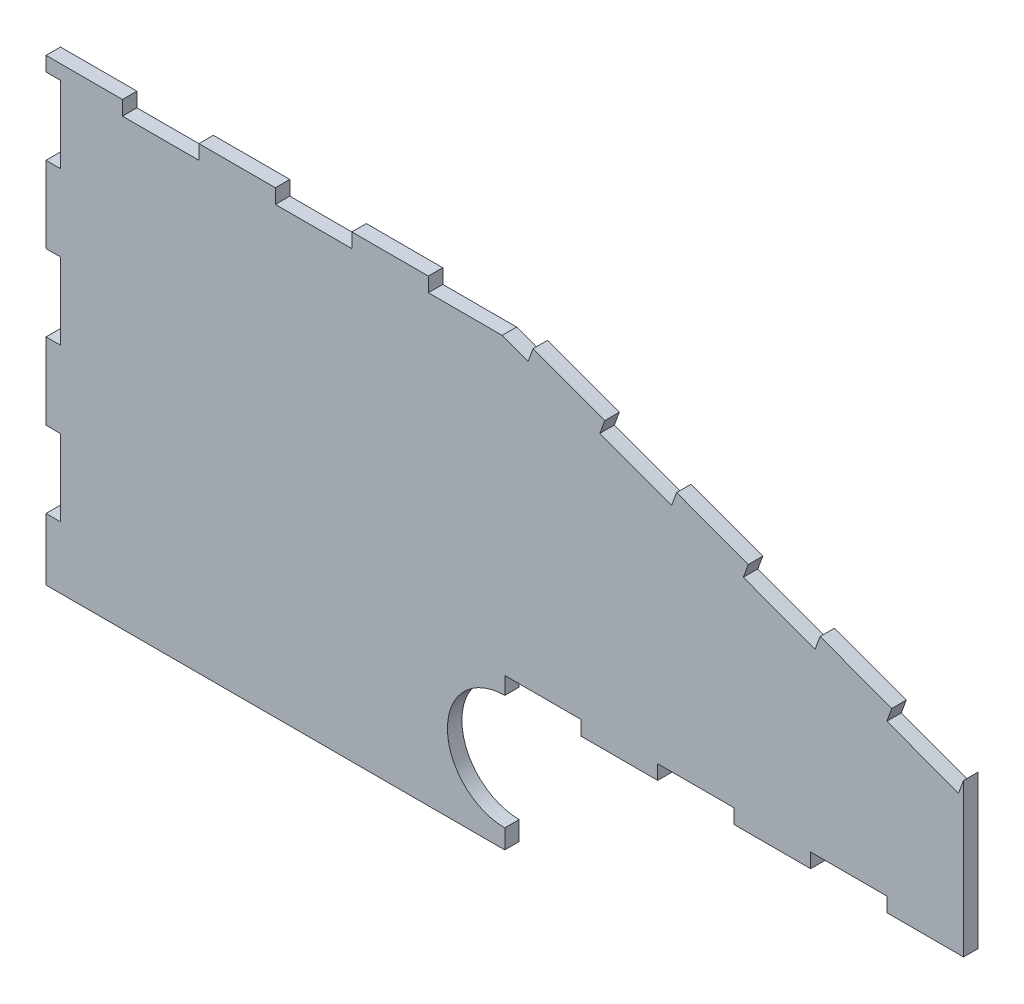
from build123d import *

# Parameters (mm, degrees)
BOSS_EXTRUDE1_DEPTH = 2.4


with BuildPart() as part:
    # Sketch1 → Boss-Extrude1 (new body)
    with BuildSketch(Plane.XY):
        with BuildLine():
            Line((-76.2, -12.7), (-76.2, -2.4))
            Line((-76.2, -2.4), (-73.8, -2.4))
            Line((-73.8, -2.4), (-73.8, 10.3))
            Line((-73.8, 10.3), (-76.2, 10.3))
            Line((-76.2, 10.3), (-76.2, 23))
            Line((-76.2, 23), (-73.8, 23))
            Line((-73.8, 23), (-73.8, 35.7))
            Line((-73.8, 35.7), (-76.2, 35.7))
            Line((-76.2, 35.7), (-76.2, 48.4))
            Line((-76.2, 48.4), (-73.8, 48.4))
            Line((-73.8, 48.4), (-73.8, 61.1))
            Line((-73.8, 61.1), (-76.2, 61.1))
            Line((-76.2, 61.1), (-76.2, 63.5))
            Line((-76.2, 63.5), (-63.5, 63.5))
            Line((-63.5, 63.5), (-63.5, 61.1))
            Line((-63.5, 61.1), (-50.8, 61.1))
            Line((-50.8, 61.1), (-50.8, 63.5))
            Line((-50.8, 63.5), (-38.1, 63.5))
            Line((-38.1, 63.5), (-38.1, 61.1))
            Line((-38.1, 61.1), (-25.4, 61.1))
            Line((-25.4, 61.1), (-25.4, 63.5))
            Line((-25.4, 63.5), (-12.7, 63.5))
            Line((-12.7, 63.5), (-12.7, 61.1))
            Line((-12.7, 61.1), (-0.428418776, 61.1))
            Line((-0.428418776, 61.1), (3.875889615, 59.512715672))
            Line((3.875889615, 59.512715672), (4.706267152, 61.764486785))
            Line((4.706267152, 61.764486785), (16.621889293, 57.370405654))
            Line((16.621889293, 57.370405654), (15.791511757, 55.118634541))
            Line((15.791511757, 55.118634541), (27.707133898, 50.72455341))
            Line((27.707133898, 50.72455341), (28.537511435, 52.976324523))
            Line((28.537511435, 52.976324523), (40.453133576, 48.582243393))
            Line((40.453133576, 48.582243393), (39.622756039, 46.330472279))
            Line((39.622756039, 46.330472279), (51.538378181, 41.936391148))
            Line((51.538378181, 41.936391148), (52.368755717, 44.188162262))
            Line((52.368755717, 44.188162262), (64.284377859, 39.794081131))
            Line((64.284377859, 39.794081131), (63.454000322, 37.542310018))
            Line((63.454000322, 37.542310018), (75.369622463, 33.148228887))
            Line((75.369622463, 33.148228887), (76.2, 35.4))
            Line((76.2, 35.4), (76.2, 10))
            Line((76.2, 10), (63.5, 10))
            Line((63.5, 10), (63.5, 12.4))
            Line((63.5, 12.4), (50.8, 12.4))
            Line((50.8, 12.4), (50.8, 10))
            Line((50.8, 10), (38.1, 10))
            Line((38.1, 10), (38.1, 12.4))
            Line((38.1, 12.4), (25.4, 12.4))
            Line((25.4, 12.4), (25.4, 10))
            Line((25.4, 10), (12.7, 10))
            Line((12.7, 10), (12.7, 12.4))
            Line((12.7, 12.4), (0, 12.4))
            Line((0, 12.4), (0, 10))
            Line((0, 10), (0, 9.525))
            ThreePointArc((0, 9.525), (-9.525, 0), (0, -9.525))
            Line((0, -9.525), (0, -12.7))
            Line((0, -12.7), (-76.2, -12.7))
        make_face()
    extrude(amount=BOSS_EXTRUDE1_DEPTH)


solid = part.part
